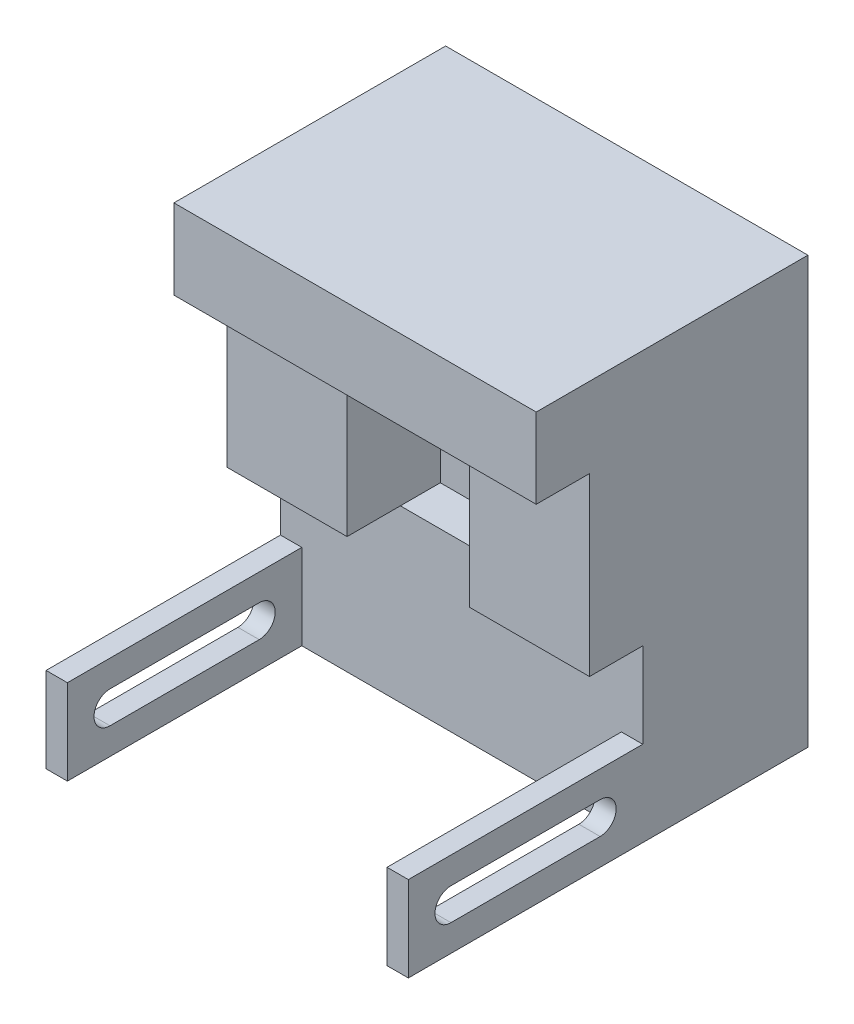
from build123d import *

# Parameters (mm, degrees)
BOSS_EXTRUDE3_DEPTH     = 51
SKETCH2_5_W             = 23
SKETCH2_5_H             = 33
BOSS_EXTRUDE4_DEPTH     = 23.5
SKETCH2_6_W             = 22.5
SKETCH2_6_H             = 33
BOSS_EXTRUDE5_DEPTH     = 41
BOSS_EXTRUDE6_DEPTH     = 31
SKETCH2_8_W             = 4
SKETCH2_8_H             = 16
BOSS_EXTRUDE7_DEPTH     = 75
CUT_EXTRUDE1_DEPTH      = 65
CUT_EXTRUDE1_DEPTH_BACK = 5


with BuildPart() as part:
    # Sketch2 → Boss-Extrude3 (new body)
    with BuildSketch(Plane.XY):
        Polygon((0, 80), (0, 65), (22.5, 65), (45.5, 65), (68, 65), (68, 80), align=None)
    extrude(amount=BOSS_EXTRUDE3_DEPTH)

    # Sketch2_5 → Boss-Extrude4 (add)
    with BuildSketch(Plane.XY):
        with Locations((34, 48.5)):
            Rectangle(SKETCH2_5_W, SKETCH2_5_H)
    extrude(amount=BOSS_EXTRUDE4_DEPTH)

    # Sketch2_6 → Boss-Extrude5 (add)
    with BuildSketch(Plane.XY):
        with Locations((56.75, 48.5)):
            Rectangle(SKETCH2_6_W, SKETCH2_6_H)
        with Locations((11.25, 48.5)):
            Rectangle(SKETCH2_6_W, SKETCH2_6_H)
    extrude(amount=BOSS_EXTRUDE5_DEPTH)

    # Sketch2_7 → Boss-Extrude6 (add)
    with BuildSketch(Plane.XY):
        Polygon((22.5, 32), (0, 32), (0, 16), (4, 16), (4, 0), (64, 0), (64, 16), (68, 16), (68, 32), (45.5, 32), align=None)
    extrude(amount=BOSS_EXTRUDE6_DEPTH)

    # Sketch2_8 → Boss-Extrude7 (add)
    with BuildSketch(Plane.XY):
        with Locations((2, 8)):
            Rectangle(SKETCH2_8_W, SKETCH2_8_H)
        with Locations((66, 8)):
            Rectangle(SKETCH2_8_W, SKETCH2_8_H)
    extrude(amount=BOSS_EXTRUDE7_DEPTH)

    # Sketch9 → Cut-Extrude1 (cut, two sides)
    with BuildSketch(Plane(origin=(4, 0, 0), x_dir=(0, 0, -1), z_dir=(1, 0, 0))) as cut_extrude1_sk:
        with BuildLine():
            Line((-67, 11), (-39, 11))
            ThreePointArc((-39, 11), (-36, 8), (-39, 5))
            Line((-39, 5), (-67, 5))
            ThreePointArc((-67, 5), (-70, 8), (-67, 11))
        make_face()
    extrude(amount=CUT_EXTRUDE1_DEPTH, mode=Mode.SUBTRACT)
    extrude(cut_extrude1_sk.sketch, amount=-CUT_EXTRUDE1_DEPTH_BACK, mode=Mode.SUBTRACT)


solid = part.part
